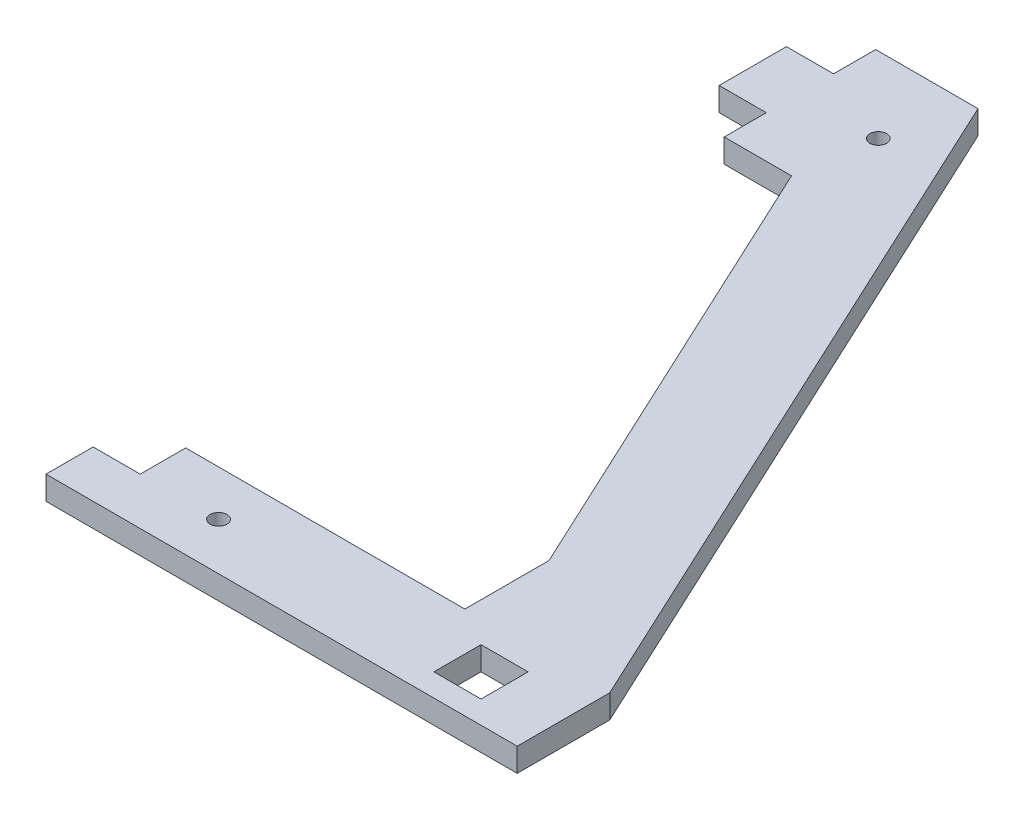
from build123d import *

# Parameters (mm, degrees)
SKETCH1_R           = 2.5
SKETCH1_W           = 14
SKETCH1_H           = 14
BOSS_EXTRUDE1_DEPTH = 7


with BuildPart() as part:
    # Sketch1 → Boss-Extrude1 (new body)
    with BuildSketch(Plane(origin=(0, 0, 0), x_dir=(1, 0, 0), z_dir=(0, 1, 0))):
        Polygon((0, 0), (0, 27.5), (-95.593069922, 232.5), (-126, 232.5), (-126, 220), (-140, 220), (-140, 200), (-126, 200), (-126, 187.5), (-106, 187.5), (-43.048466149, 52.5), (-43.048466149, 27.5), (-126, 27.5), (-126, 14), (-140, 14), (-140, 0), align=None)
        with Locations((-102.73, 14)):
            Circle(SKETCH1_R, mode=Mode.SUBTRACT)
        with Locations((-102.73, 210)):
            Circle(SKETCH1_R, mode=Mode.SUBTRACT)
        with Locations((-24.5, 13.75)):
            Rectangle(SKETCH1_W, SKETCH1_H, mode=Mode.SUBTRACT)
    extrude(amount=BOSS_EXTRUDE1_DEPTH)


solid = part.part
